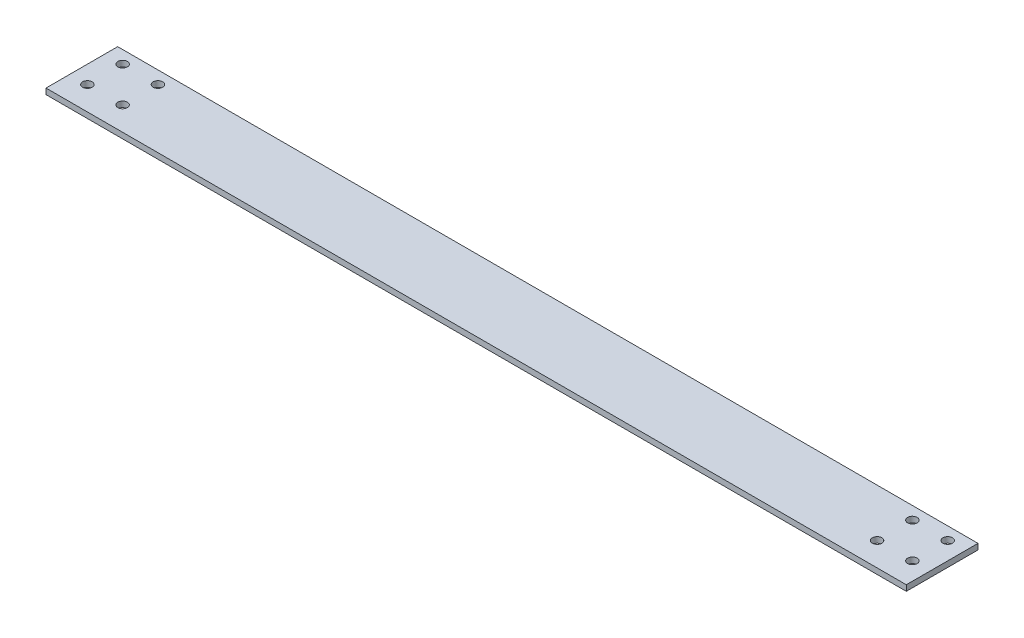
from build123d import *

# Parameters (mm, degrees)
SKETCH1_W               = 609.6
SKETCH1_H               = 43.8
SKETCH1_H_2             = 7
BOSS_EXTRUDE1_DEPTH     = 4.064
F_1_4_CLEARANCE_HOLE1_D = 6.7564


with BuildPart() as part:
    # Sketch1 → Boss-Extrude1 (new body)
    with BuildSketch(Plane(origin=(0, 0, 0), x_dir=(1, 0, 0), z_dir=(0, 1, 0))):
        with Locations((304.8, 28.9)):
            Rectangle(SKETCH1_W, SKETCH1_H)
        with Locations((304.8, 3.5)):
            Rectangle(SKETCH1_W, SKETCH1_H_2)
    extrude(amount=BOSS_EXTRUDE1_DEPTH)

    # 1/4 Clearance Hole1 (through all)
    with Locations(Plane(origin=(0, 0, 0), x_dir=(-1, 0, 0), z_dir=(0, -1, 0))):
        with Locations((-12.5, 41.8), (-37.5, 41.8), (-37.5, 16.8), (-12.5, 16.8), (-572.1, 41.8), (-597.1, 41.8), (-597.1, 16.8), (-572.1, 16.8)):
            Hole(F_1_4_CLEARANCE_HOLE1_D / 2)


solid = part.part
